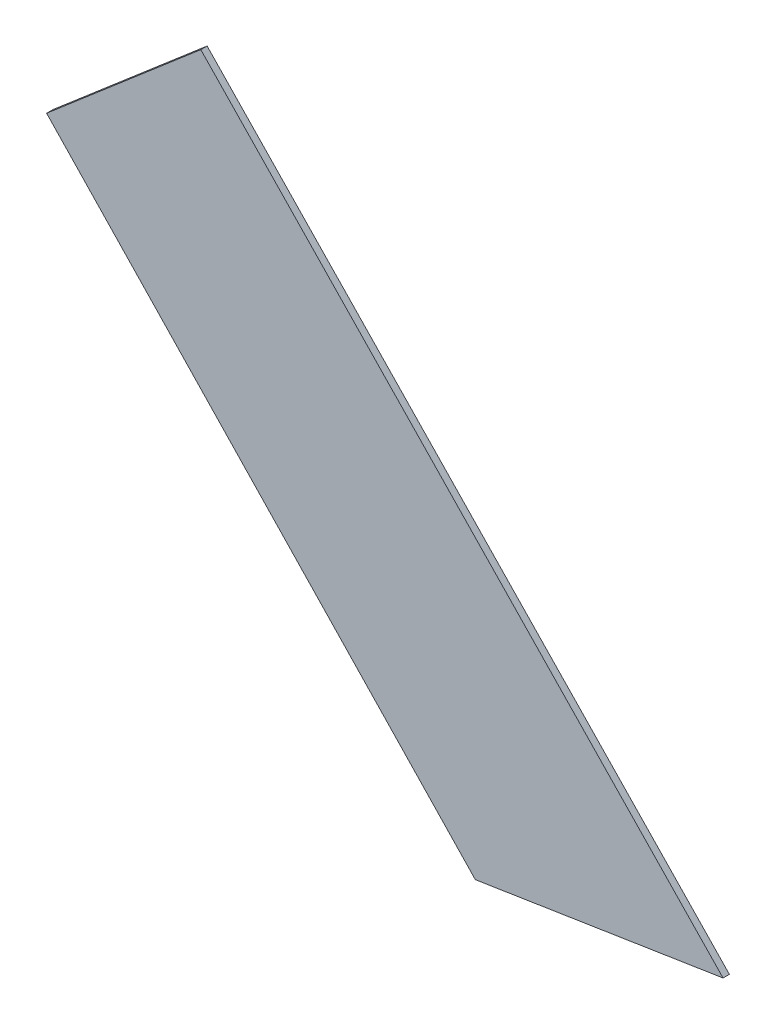
from build123d import *

# Parameters (mm, degrees)
SALIENTE_EXTRUIR1_DEPTH = 0.1


with BuildPart() as part:
    # Model → Saliente-Extruir1 (new body)
    with BuildSketch(Plane.XY):
        Polygon((35.144226194, 12.017267261), (31.229857019, 11.40547106), (24.455773806, 18.506341556), (26.891992421, 20.59452894), align=None)
    extrude(amount=SALIENTE_EXTRUIR1_DEPTH)


solid = part.part
